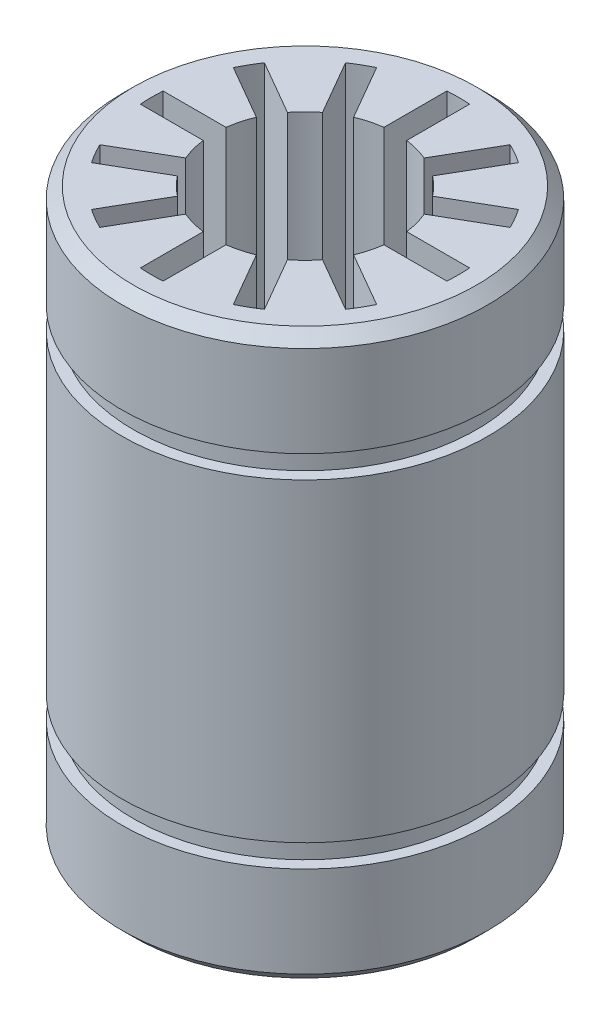
from build123d import *

# Parameters (mm, degrees)
CHANFREIN1_SIZE         = 0.5
ENL_V_MAT_EXTRU_1_DEPTH = 25.8


with BuildPart() as part:
    # Esquisse2 → Révolution1 (revolve)
    with BuildSketch(Plane.XY):
        Polygon((0, 12.4), (-8.03826441, 12.4), (-8.03826441, 7.9), (-7.53826441, 7.9), (-7.53826441, 6.9), (-8.03826441, 6.9), (-8.03826441, -6.9), (-7.53826441, -6.9), (-7.53826441, -7.9), (-8.03826441, -7.9), (-8.03826441, -12.4), (0, -12.4), align=None)
    revolve(axis=Axis((0, 0, 0), (0, -1, 0)))

    # Chanfrein1
    chanfrein1_edges = [part.edges().sort_by_distance(p)[0] for p in [
        (8.03826441, 12.4, 0),
        (8.03826441, -12.4, 0),
    ]]
    chamfer(chanfrein1_edges, length=CHANFREIN1_SIZE)

    # Esquisse3 → Enlèv. mat.-Extru.1 (cut, through all)
    with BuildSketch(Plane(origin=(0, 12.4, 0), x_dir=(1, 0, 0), z_dir=(0, 1, 0))):
        with BuildLine():
            Line((-0.5, 6.731456009), (-0.5, 3.968626967))
            ThreePointArc((-0.5, 3.968626967), (-1.03527618, 3.863703305), (-1.551300781, 3.686931771))
            Line((-1.551300781, 3.686931771), (-2.932715303, 6.079611908))
            ThreePointArc((-2.932715303, 6.079611908), (-3.375, 5.845671476), (-3.798740706, 5.579611908))
            Line((-3.798740706, 5.579611908), (-2.417326185, 3.186931771))
            ThreePointArc((-2.417326185, 3.186931771), (-2.828427125, 2.828427125), (-3.186931771, 2.417326185))
            Line((-3.186931771, 2.417326185), (-5.579611908, 3.798740706))
            ThreePointArc((-5.579611908, 3.798740706), (-5.845671476, 3.375), (-6.079611908, 2.932715303))
            Line((-6.079611908, 2.932715303), (-3.686931771, 1.551300781))
            ThreePointArc((-3.686931771, 1.551300781), (-3.863703305, 1.03527618), (-3.968626967, 0.5))
            Line((-3.968626967, 0.5), (-6.731456009, 0.5))
            ThreePointArc((-6.731456009, 0.5), (-6.75, 0), (-6.731456009, -0.5))
            Line((-6.731456009, -0.5), (-3.968626967, -0.5))
            ThreePointArc((-3.968626967, -0.5), (-3.863703305, -1.03527618), (-3.686931771, -1.551300781))
            Line((-3.686931771, -1.551300781), (-6.079611908, -2.932715303))
            ThreePointArc((-6.079611908, -2.932715303), (-5.845671476, -3.375), (-5.579611908, -3.798740706))
            Line((-5.579611908, -3.798740706), (-3.186931771, -2.417326185))
            ThreePointArc((-3.186931771, -2.417326185), (-2.828427125, -2.828427125), (-2.417326185, -3.186931771))
            Line((-2.417326185, -3.186931771), (-3.798740706, -5.579611908))
            ThreePointArc((-3.798740706, -5.579611908), (-3.375, -5.845671476), (-2.932715303, -6.079611908))
            Line((-2.932715303, -6.079611908), (-1.551300781, -3.686931771))
            ThreePointArc((-1.551300781, -3.686931771), (-1.03527618, -3.863703305), (-0.5, -3.968626967))
            Line((-0.5, -3.968626967), (-0.5, -6.731456009))
            ThreePointArc((-0.5, -6.731456009), (0, -6.75), (0.5, -6.731456009))
            Line((0.5, -6.731456009), (0.5, -3.968626967))
            ThreePointArc((0.5, -3.968626967), (1.03527618, -3.863703305), (1.551300781, -3.686931771))
            Line((1.551300781, -3.686931771), (2.932715303, -6.079611908))
            ThreePointArc((2.932715303, -6.079611908), (3.375, -5.845671476), (3.798740706, -5.579611908))
            Line((3.798740706, -5.579611908), (2.417326185, -3.186931771))
            ThreePointArc((2.417326185, -3.186931771), (2.828427125, -2.828427125), (3.186931771, -2.417326185))
            Line((3.186931771, -2.417326185), (5.579611908, -3.798740706))
            ThreePointArc((5.579611908, -3.798740706), (5.845671476, -3.375), (6.079611908, -2.932715303))
            Line((6.079611908, -2.932715303), (3.686931771, -1.551300781))
            ThreePointArc((3.686931771, -1.551300781), (3.863703305, -1.03527618), (3.968626967, -0.5))
            Line((3.968626967, -0.5), (6.731456009, -0.5))
            ThreePointArc((6.731456009, -0.5), (6.75, 0), (6.731456009, 0.5))
            Line((6.731456009, 0.5), (3.968626967, 0.5))
            ThreePointArc((3.968626967, 0.5), (3.863703305, 1.03527618), (3.686931771, 1.551300781))
            Line((3.686931771, 1.551300781), (6.079611908, 2.932715303))
            ThreePointArc((6.079611908, 2.932715303), (5.845671476, 3.375), (5.579611908, 3.798740706))
            Line((5.579611908, 3.798740706), (3.186931771, 2.417326185))
            ThreePointArc((3.186931771, 2.417326185), (2.828427125, 2.828427125), (2.417326185, 3.186931771))
            Line((2.417326185, 3.186931771), (3.798740706, 5.579611908))
            ThreePointArc((3.798740706, 5.579611908), (3.375, 5.845671476), (2.932715303, 6.079611908))
            Line((2.932715303, 6.079611908), (1.551300781, 3.686931771))
            ThreePointArc((1.551300781, 3.686931771), (1.03527618, 3.863703305), (0.5, 3.968626967))
            Line((0.5, 3.968626967), (0.5, 6.731456009))
            ThreePointArc((0.5, 6.731456009), (0, 6.75), (-0.5, 6.731456009))
        make_face()
    extrude(amount=-ENL_V_MAT_EXTRU_1_DEPTH, mode=Mode.SUBTRACT)


solid = part.part
